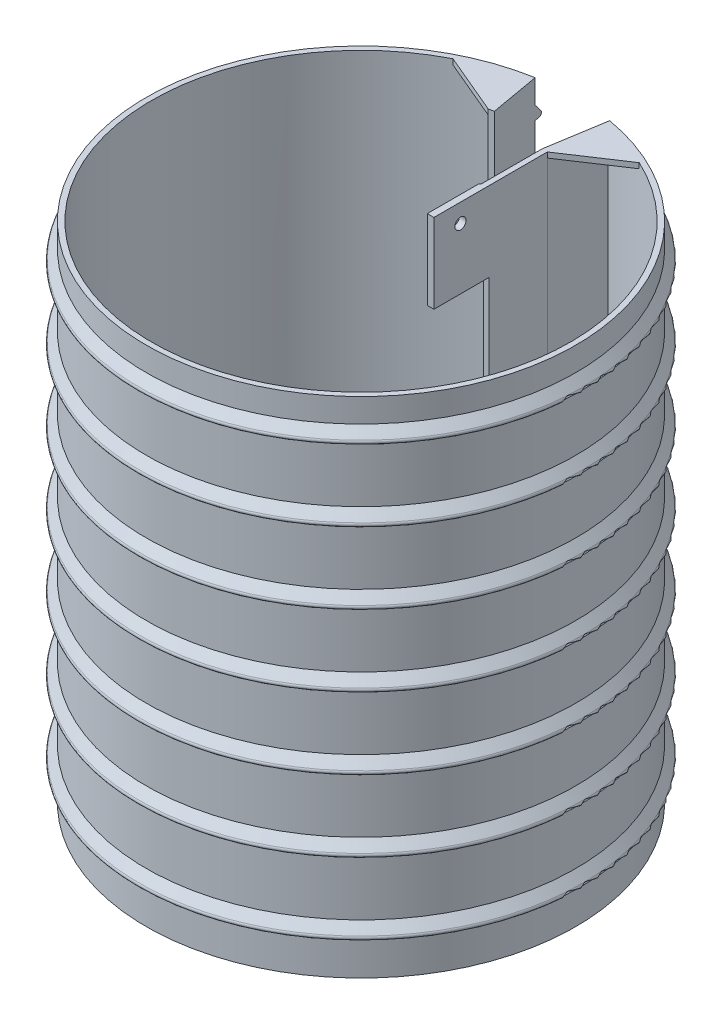
from build123d import *

# Parameters (mm, degrees)
RESSALTO_EXTRUS_O1_DEPTH = 190
PADR_O_LINEAR1_COUNT     = 7
PADR_O_LINEAR1_PITCH     = 27
RESSALTO_EXTRUS_O2_DEPTH = 30
CORTE_EXTRUS_O1_REACH    = 98.419
ESBO_O5_R                = 2.1
RESSALTO_EXTRUS_O3_DEPTH = 165
RESSALTO_EXTRUS_O4_DEPTH = 2


with BuildPart() as part:
    # Esboço1 → Ressalto-extrusão1 (new body)
    with BuildSketch(Plane(origin=(0, 0, 0), x_dir=(1, 0, 0), z_dir=(0, 1, 0))):
        with BuildLine():
            Line((-13.718206036, 77.799812488), (-14.065502391, 79.769427994))
            ThreePointArc((-14.065502391, 79.769427994), (0, -81), (14.065502391, 79.769427994))
            Line((14.065502391, 79.769427994), (13.718206036, 77.799812488))
            Line((13.718206036, 77.799812488), (10.5, 57.8))
            Line((10.5, 57.8), (10.5, 35.8))
            Line((10.5, 35.8), (12.5, 35.8))
            Line((12.5, 35.8), (12.5, 57.8))
            Line((12.5, 57.8), (15.659101617, 77.432503101))
            ThreePointArc((15.659101617, 77.432503101), (-0.987673003, -78.993825721), (-13.718206036, 77.799812488))
        make_face()
    extrude(amount=RESSALTO_EXTRUS_O1_DEPTH)

    # Varredura1: sweep along a path in Esboço3
    with BuildLine(Plane(origin=(0, 13, 0), x_dir=(1, 0, 0), z_dir=(0, 1, 0))) as varredura1_path:
        ThreePointArc((-14.15232648, 80.26183187), (0, -81.5), (14.15232648, 80.26183187))
    # Esboço2 → Varredura1 (sweep)
    with BuildSketch(Plane(origin=(0, 0, 0), x_dir=(-0.173648178, 0, -0.984807753), z_dir=(0.984807753, 0, -0.173648178))):
        with BuildLine():
            Line((81, 14), (82.919375153, 14))
            ThreePointArc((82.919375153, 14), (83.820678389, 14.56681127), (83.700243962, 15.624695048))
            Line((83.700243962, 15.624695048), (81, 19))
            Line((81, 19), (81, 14))
        make_face()
    varredura1 = sweep(path=varredura1_path.line)

    # Padrão linear1: Varredura1 ×7
    with Locations(*[(0, i * PADR_O_LINEAR1_PITCH, 0) for i in range(1, PADR_O_LINEAR1_COUNT)]):
        add(varredura1)

    # Esboço4 → Ressalto-extrusão2 (add)
    with BuildSketch(Plane(origin=(0, 190, 0), x_dir=(1, 0, 0), z_dir=(0, 1, 0))):
        Polygon((10.5, 35.8), (10.5, 35), (10, 34.5), (10, 15), (12.5, 15), (12.5, 35.8), align=None)
    extrude(amount=-RESSALTO_EXTRUS_O2_DEPTH)

    # Esboço5 → Corte-extrusão1 (cut, up to next)
    with BuildSketch(Plane(origin=(12.5, 0, 0), x_dir=(0, 0, -1), z_dir=(1, 0, 0)), mode=Mode.PRIVATE) as corte_extrus_o1_sk1:
        with Locations((25, 183)):
            Circle(ESBO_O5_R)
    corte_extrus_o1_tool1 = extrude(corte_extrus_o1_sk1.sketch, amount=-CORTE_EXTRUS_O1_REACH, mode=Mode.PRIVATE) & part.part
    add(corte_extrus_o1_tool1.solids().sort_by_distance((12.5, 183, -25))[0], mode=Mode.SUBTRACT)

    # Esboço6 → Ressalto-extrusão3 (add)
    with BuildSketch(Plane(origin=(0, 190, 0), x_dir=(1, 0, 0), z_dir=(0, 1, 0))):
        with BuildLine():
            Line((-13.718206036, 77.799812488), (-10.766187015, 61.058080687))
            Line((-10.766187015, 61.058080687), (-12.735802521, 60.710784331))
            Line((-12.735802521, 60.710784331), (-16.219440766, 77.317072767))
            ThreePointArc((-16.219440766, 77.317072767), (-14.970769299, 77.568524974), (-13.718206036, 77.799812488))
        make_face()
    extrude(amount=-RESSALTO_EXTRUS_O3_DEPTH)

    # Esboço7 → Ressalto-extrusão4 (add)
    with BuildSketch(Plane(origin=(0, 190, 0), x_dir=(1, 0, 0), z_dir=(0, 1, 0))):
        with BuildLine():
            Line((12.5, 57.8), (33.329519809, 71.625017342))
            ThreePointArc((33.329519809, 71.625017342), (24.665826157, 75.050629711), (15.659101617, 77.432503101))
            Line((15.659101617, 77.432503101), (12.5, 57.8))
        make_face()
        with BuildLine():
            Line((-35.764684752, 70.440665276), (-12.735802521, 60.710784331))
            Line((-12.735802521, 60.710784331), (-16.219440766, 77.317072767))
            ThreePointArc((-16.219440766, 77.317072767), (-26.218477672, 74.522422321), (-35.764684752, 70.440665276))
        make_face()
    extrude(amount=-RESSALTO_EXTRUS_O4_DEPTH)


solid = part.part
